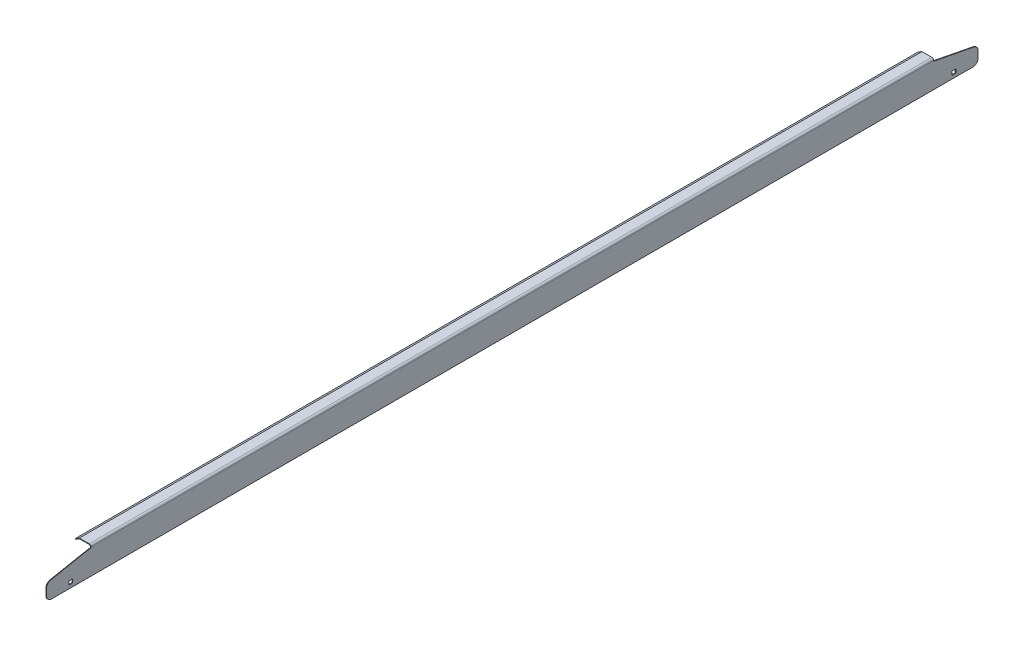
from build123d import *

# Parameters (mm, degrees)
EXTRUDE1_DEPTH     = 599.28125
CUT_EXTRUDE1_DEPTH = 25.4
CUT_EXTRUDE2_DEPTH = 25.4
CUT_EXTRUDE3_DEPTH = 25.4
SKETCH5_W          = 4.7625
SKETCH5_H          = 4.7625
CUT_EXTRUDE4_DEPTH = 0.79375
FILLET1_R          = 6.35


with BuildPart() as part:
    # Sketch1 → Extrude1 (new body, symmetric)
    with BuildSketch(Plane.XY):
        with BuildLine():
            Line((1143, 0), (1142.20625, 0))
            Line((1142.20625, 0), (1142.20625, 32.54375))
            ThreePointArc((1142.20625, 32.54375), (1141.741282015, 33.666282015), (1140.61875, 34.13125))
            Line((1140.61875, 34.13125), (1128.140506397, 34.13125))
            Line((1128.140506397, 34.13125), (1123.091401986, 31.071186722))
            Line((1123.091401986, 31.071186722), (1122.68, 31.75))
            Line((1122.68, 31.75), (1127.91875, 34.925))
            Line((1127.91875, 34.925), (1140.61875, 34.925))
            ThreePointArc((1140.61875, 34.925), (1142.302548023, 34.227548023), (1143, 32.54375))
            Line((1143, 32.54375), (1143, 0))
        make_face()
    extrude(amount=EXTRUDE1_DEPTH, both=True)

    # Sketch2 → Cut-Extrude1 (cut)
    with BuildSketch(Plane(origin=(1143, 0, 0), x_dir=(0, 0, -1), z_dir=(1, 0, 0))):
        Polygon((599.28125, 34.925), (542.13125, 34.925), (542.13125, 31.75), (599.28125, 20.6502), align=None)
        Polygon((-599.28125, 34.925), (-542.13125, 34.925), (-542.13125, 31.75), (-599.28125, 20.6502), align=None)
    extrude(amount=-CUT_EXTRUDE1_DEPTH, mode=Mode.SUBTRACT)

    # Sketch3 → Cut-Extrude2 (cut)
    with BuildSketch(Plane(origin=(0, 0, -542.13125), x_dir=(-1, 0, 0), z_dir=(0, 0, -1))):
        Polygon((-1127.91875, 34.925), (-1122.68, 31.75), (-1123.420434334, 30.528283348), (-1128.140506397, 34.13125), align=None)
    extrude(amount=CUT_EXTRUDE2_DEPTH, mode=Mode.SUBTRACT)

    # Sketch4 → Cut-Extrude3 (cut)
    with BuildSketch(Plane.XY.offset(542.13125)):
        Polygon((1127.91875, 34.925), (1122.68, 31.75), (1124.000635951, 29.570950682), (1128.140506397, 34.13125), align=None)
    extrude(amount=CUT_EXTRUDE3_DEPTH, mode=Mode.SUBTRACT)

    # Sketch5 → Cut-Extrude4 (cut)
    with BuildSketch(Plane(origin=(1143, 0, 0), x_dir=(0, 0, -1), z_dir=(1, 0, 0))):
        with Locations((568.325, 6.62305)):
            Rectangle(SKETCH5_W, SKETCH5_H)
        with Locations((-568.325, 6.62305)):
            Rectangle(SKETCH5_W, SKETCH5_H)
    extrude(amount=-CUT_EXTRUDE4_DEPTH, mode=Mode.SUBTRACT)

    # Fillet1
    fillet1_edges = [part.edges().sort_by_distance(p)[0] for p in [
        (1142.603125, 20.6502, -599.28125),
        (1142.603125, 0, 599.28125),
        (1142.603125, 20.6502, 599.28125),
        (1142.603125, 0, -599.28125),
    ]]
    fillet(fillet1_edges, radius=FILLET1_R)


solid = part.part
